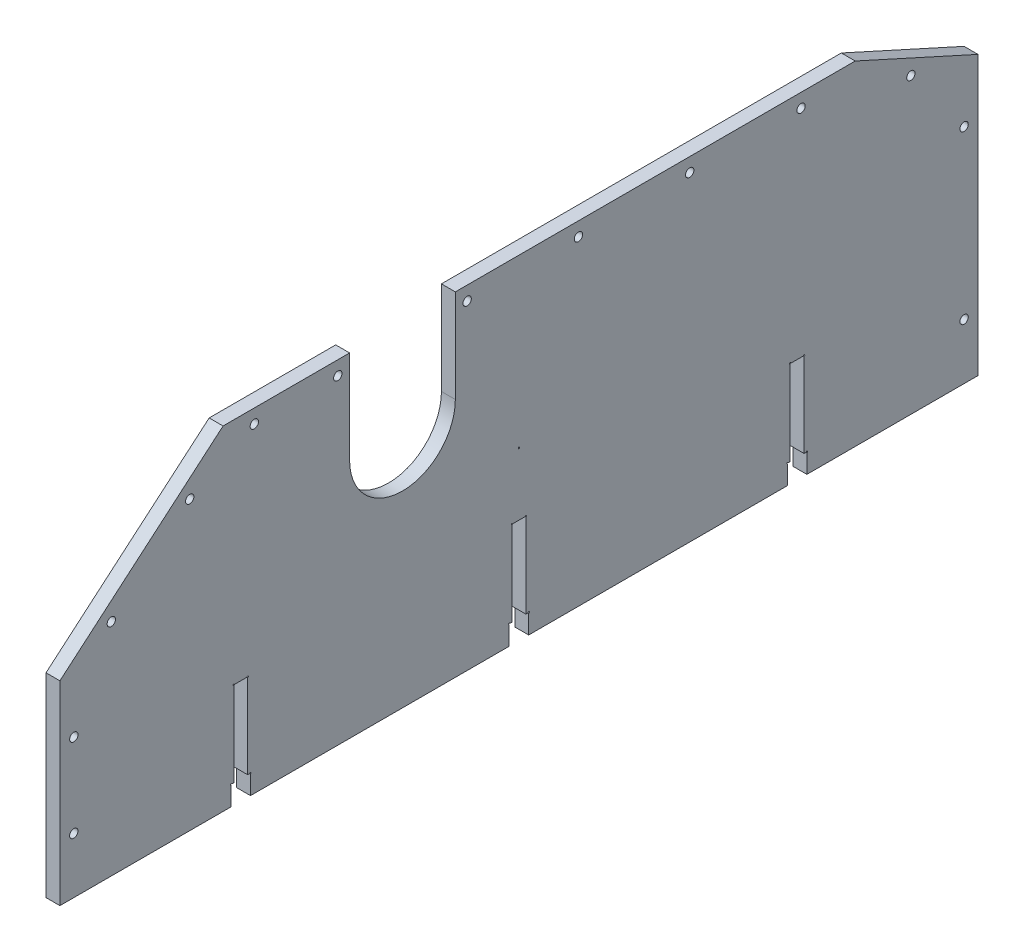
from build123d import *

# Parameters (mm, degrees)
ESTRUSIONE_ESTRUSIONE1_DEPTH = 5
TAGLIO_ESTRUSIONE5_DEPTH     = 6
SCHIZZO2_W                   = 5
SCHIZZO2_H                   = 37.5
TAGLIO_ESTRUSIONE1_DEPTH     = 6
SCHIZZO3_R                   = 1.5
TAGLIO_ESTRUSIONE2_DEPTH     = 6
SCHIZZO8_W                   = 7
SCHIZZO8_H                   = 7
TAGLIO_ESTRUSIONE6_DEPTH     = 6
SCHIZZO10_R                  = 0.25
TAGLIO_ESTRUSIONE11_DEPTH    = 6


with BuildPart() as part:
    # Schizzo1 → Estrusione-Estrusione1 (new body)
    with BuildSketch(Plane(origin=(0, 0, 0), x_dir=(0, 0, -1), z_dir=(1, 0, 0))):
        Polygon((165, 60), (-106.353966324, 60), (-165, 10), (-165, -60), (165, -60), align=None)
    extrude(amount=ESTRUSIONE_ESTRUSIONE1_DEPTH)

    # Schizzo7 → Taglio-Estrusione5 (cut, through all)
    with BuildSketch(Plane(origin=(0, 0, 0), x_dir=(0, 0, -1), z_dir=(1, 0, 0))):
        Polygon((165, 40), (165, 60), (120.869304328, 60), align=None)
    extrude(amount=TAGLIO_ESTRUSIONE5_DEPTH, mode=Mode.SUBTRACT)

    # Schizzo2 → Taglio-Estrusione1 (cut, through all)
    with BuildSketch(Plane(origin=(5, 0, 0), x_dir=(0, 0, -1), z_dir=(1, 0, 0))):
        with Locations((100, -41.25)):
            Rectangle(SCHIZZO2_W, SCHIZZO2_H)
        with Locations((0, -41.25)):
            Rectangle(SCHIZZO2_W, SCHIZZO2_H)
        with Locations((-100, -41.25)):
            Rectangle(SCHIZZO2_W, SCHIZZO2_H)
    extrude(amount=-TAGLIO_ESTRUSIONE1_DEPTH, mode=Mode.SUBTRACT)

    # Schizzo3 → Taglio-Estrusione2 (cut, through all)
    with BuildSketch(Plane(origin=(0, 0, 0), x_dir=(0, 0, -1), z_dir=(1, 0, 0))):
        with Locations((-65.12, 55)):
            Circle(SCHIZZO3_R)
        with Locations((-18.62, 55)):
            Circle(SCHIZZO3_R)
        with Locations((-95.12, 55)):
            Circle(SCHIZZO3_R)
        with Locations((21.38, 55)):
            Circle(SCHIZZO3_R)
        with Locations((61.38, 55)):
            Circle(SCHIZZO3_R)
        with Locations((101.38, 55)):
            Circle(SCHIZZO3_R)
        with Locations((-118.329493742, 43.219453434)):
            Circle(SCHIZZO3_R)
        with Locations((-146.536630365, 19.170822303)):
            Circle(SCHIZZO3_R)
        with Locations((-160, -10)):
            Circle(SCHIZZO3_R)
        with Locations((-160, -40)):
            Circle(SCHIZZO3_R)
        with Locations((160, -40)):
            Circle(SCHIZZO3_R)
        with Locations((160, 20)):
            Circle(SCHIZZO3_R)
        with Locations((140.870719583, 45.44586097)):
            Circle(SCHIZZO3_R)
        with BuildLine():
            Line((-60.87, 26.5), (-60.87, 60))
            ThreePointArc((-60.87, 60), (-41.87, 79), (-22.87, 60))
            Line((-22.87, 60), (-22.87, 26.5))
            ThreePointArc((-22.87, 26.5), (-41.87, 7.5), (-60.87, 26.5))
        make_face()
    extrude(amount=TAGLIO_ESTRUSIONE2_DEPTH, mode=Mode.SUBTRACT)

    # Schizzo8 → Taglio-Estrusione6 (cut, through all)
    with BuildSketch(Plane(origin=(5, 0, 0), x_dir=(0, 0, -1), z_dir=(1, 0, 0))):
        with Locations((0, -56.5)):
            Rectangle(SCHIZZO8_W, SCHIZZO8_H)
        with Locations((100, -56.5)):
            Rectangle(SCHIZZO8_W, SCHIZZO8_H)
        with Locations((-100, -56.5)):
            Rectangle(SCHIZZO8_W, SCHIZZO8_H)
    extrude(amount=-TAGLIO_ESTRUSIONE6_DEPTH, mode=Mode.SUBTRACT)

    # Schizzo10 → Taglio-Estrusione11 (cut, through all)
    with BuildSketch(Plane(origin=(0, 0, 0), x_dir=(0, 0, -1), z_dir=(1, 0, 0))):
        with Locations((-102.5, -22.5)):
            Circle(SCHIZZO10_R)
        with Locations((-97.5, -22.5)):
            Circle(SCHIZZO10_R)
        with Locations((-103.5, -53)):
            Circle(SCHIZZO10_R)
        with Locations((-96.5, -53)):
            Circle(SCHIZZO10_R)
        with Locations((-2.5, -22.5)):
            Circle(SCHIZZO10_R)
        Circle(SCHIZZO10_R)
        with Locations((2.5, -22.5)):
            Circle(SCHIZZO10_R)
        with Locations((-3.5, -53)):
            Circle(SCHIZZO10_R)
        with Locations((3.5, -53)):
            Circle(SCHIZZO10_R)
        with Locations((97.5, -22.5)):
            Circle(SCHIZZO10_R)
        with Locations((102.5, -22.5)):
            Circle(SCHIZZO10_R)
        with Locations((96.5, -53)):
            Circle(SCHIZZO10_R)
        with Locations((103.5, -53)):
            Circle(SCHIZZO10_R)
    extrude(amount=TAGLIO_ESTRUSIONE11_DEPTH, mode=Mode.SUBTRACT)


solid = part.part
